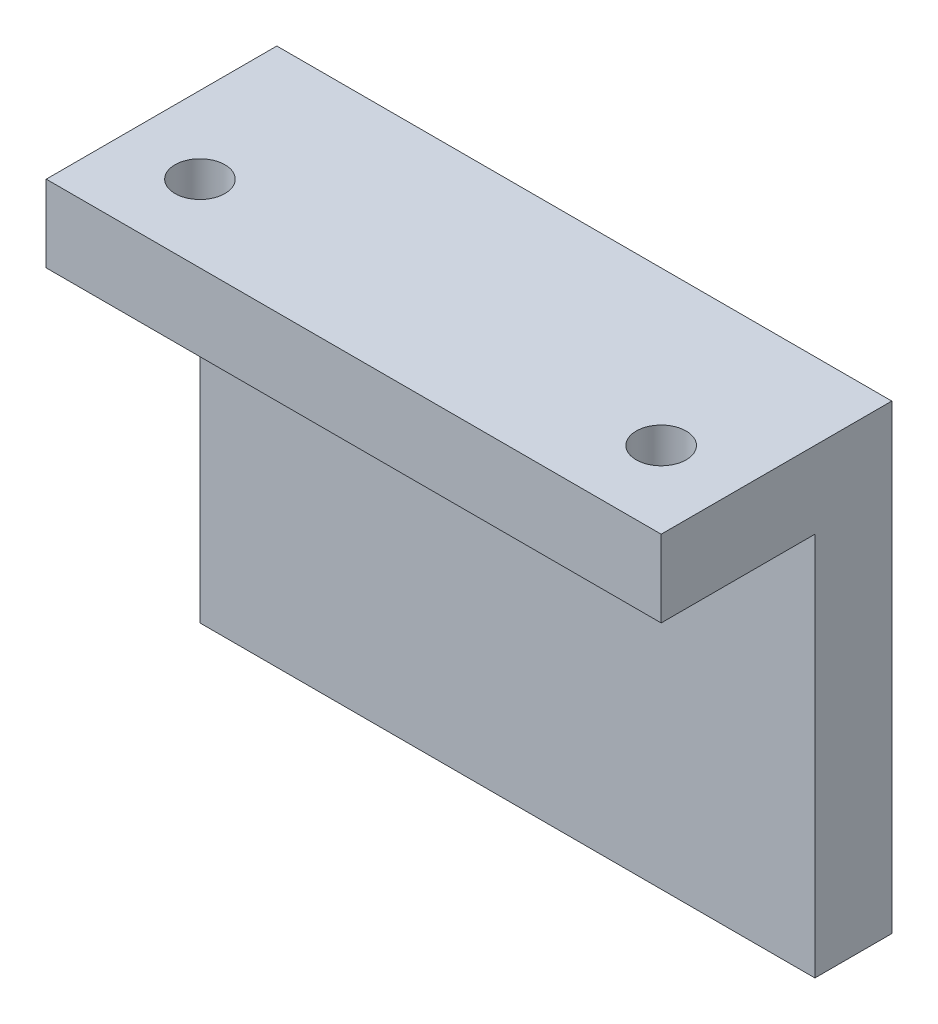
from build123d import *

# Parameters (mm, degrees)
ESQUISSE1_W             = 40
ESQUISSE1_H             = 30
BOSS_EXTRU_1_DEPTH      = 5
ESQUISSE2_W             = 40
ESQUISSE2_H             = 5
BOSS_EXTRU_2_DEPTH      = 10
ESQUISSE3_R             = 1.625
ENL_V_MAT_EXTRU_1_DEPTH = 6
ESQUISSE4_R             = 2.6
ENL_V_MAT_EXTRU_2_DEPTH = 4


with BuildPart() as part:
    # Esquisse1 → Boss.-Extru.1 (new body)
    with BuildSketch(Plane.XY):
        with Locations((20, -15)):
            Rectangle(ESQUISSE1_W, ESQUISSE1_H)
    extrude(amount=BOSS_EXTRU_1_DEPTH)

    # Esquisse2 → Boss.-Extru.2 (add)
    with BuildSketch(Plane.XY.offset(5)):
        with Locations((20, -2.5)):
            Rectangle(ESQUISSE2_W, ESQUISSE2_H)
    extrude(amount=BOSS_EXTRU_2_DEPTH)

    # Esquisse3 → Enlèv. mat.-Extru.1 (cut, through all)
    with BuildSketch(Plane.XZ.offset(5)):
        with Locations((5, 10)):
            Circle(ESQUISSE3_R)
        with Locations((35, 10)):
            Circle(ESQUISSE3_R)
    extrude(amount=-ENL_V_MAT_EXTRU_1_DEPTH, mode=Mode.SUBTRACT)

    # Esquisse4 → Enlèv. mat.-Extru.2 (cut)
    with BuildSketch(Plane(origin=(0, 0, 0), x_dir=(-1, 0, 0), z_dir=(0, 0, -1))):
        with Locations((-9.1, -20.9)):
            Circle(ESQUISSE4_R)
    extrude(amount=-ENL_V_MAT_EXTRU_2_DEPTH, mode=Mode.SUBTRACT)


solid = part.part
